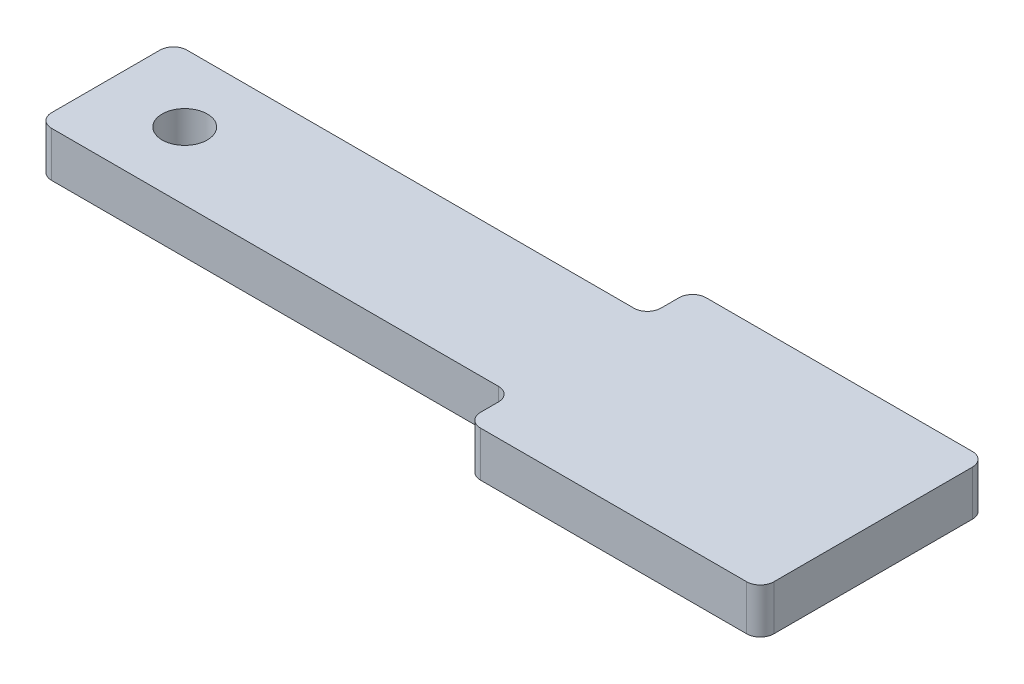
from build123d import *

# Parameters (mm, degrees)
SKETCH1_R           = 0.5
BOSS_EXTRUDE1_DEPTH = 1
FILLET1_R           = 0.3


with BuildPart() as part:
    # Sketch1 → Boss-Extrude1 (new body)
    with BuildSketch(Plane(origin=(0, 0, 0), x_dir=(1, 0, 0), z_dir=(0, 1, 0))):
        Polygon((-4.5, 0), (-15, 0), (-15, 3), (-4.5, 3), (-4.5, 4), (2, 4), (2, -1), (-4.5, -1), align=None)
        with Locations((-13.25, 1.5)):
            Circle(SKETCH1_R, mode=Mode.SUBTRACT)
    extrude(amount=BOSS_EXTRUDE1_DEPTH)

    # Fillet1
    fillet1_edges = [part.edges().sort_by_distance(p)[0] for p in [
        (-15, 0.5, -3),
        (-4.5, 0.5, -3),
        (-4.5, 0.5, -4),
        (2, 0.5, -4),
        (2, 0.5, 1),
        (-4.5, 0.5, 1),
        (-4.5, 0.5, 0),
        (-15, 0.5, 0),
    ]]
    fillet(fillet1_edges, radius=FILLET1_R)


solid = part.part
